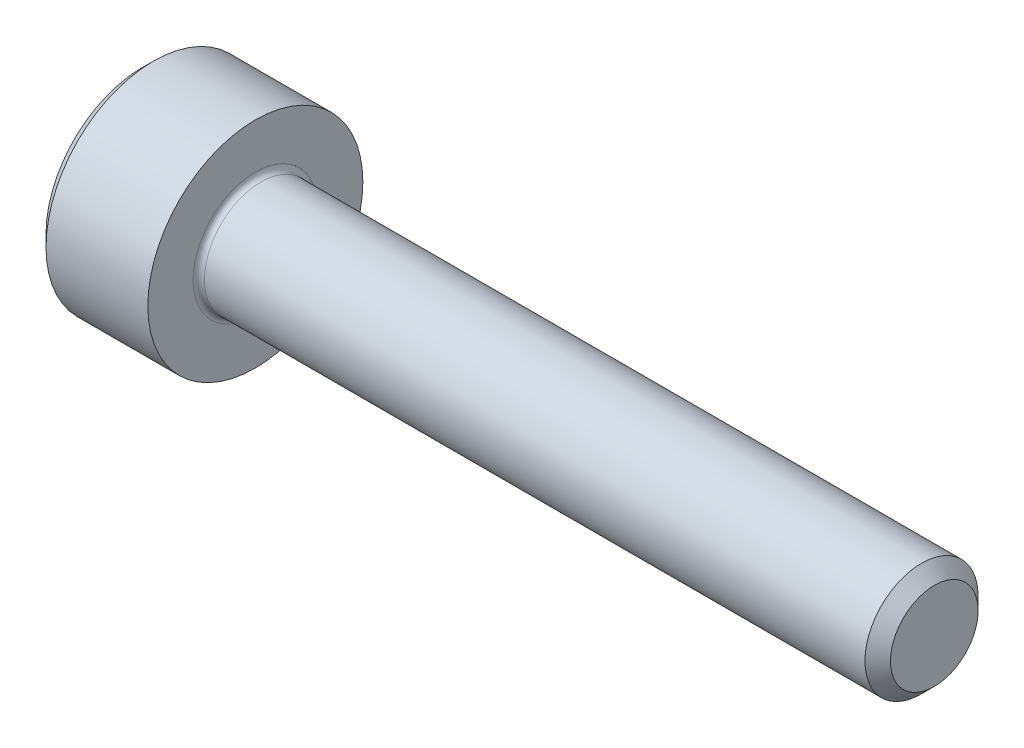
from build123d import *

# Parameters (mm, degrees)
FILLET1_R   = 0.1
HEX_2_DEPTH = 1


with BuildPart() as part:
    # BodySke → Base-Revolve (revolve)
    with BuildSketch(Plane.XY):
        Polygon((0, 0), (0, 1.7), (0.2, 1.9), (2, 1.9), (2, 1), (13.774, 1), (14, 0.774), (14, 0), align=None)
    revolve(axis=Axis((-31.75, 0, 0), (1, 0, 0)))

    # Fillet1
    fillet1_edges = [part.edges().sort_by_distance(p)[0] for p in [
        (2, -1, 0),
    ]]
    fillet(fillet1_edges, radius=FILLET1_R)

    # Sketch2 → Hex-PreBroach (revolve, cut)
    with BuildSketch(Plane.XY):
        Polygon((0, 0.7725), (1, 0.7725), (1.446003083, 0), (0, 0), align=None)
    revolve(axis=Axis((0, 0, 0), (1, 0, 0)), mode=Mode.SUBTRACT)

    # Sketch3 → Hex 2 (cut)
    with BuildSketch(Plane(origin=(0, 0, 0), x_dir=(0, 0.5, 0.866025404), z_dir=(-1, 0, 0))):
        Polygon((0.446003083, 0.7725), (-0.446003083, 0.7725), (-0.892006166, 0), (-0.446003083, -0.7725), (0.446003083, -0.7725), (0.892006166, 0), align=None)
    extrude(amount=-HEX_2_DEPTH, mode=Mode.SUBTRACT)


solid = part.part
